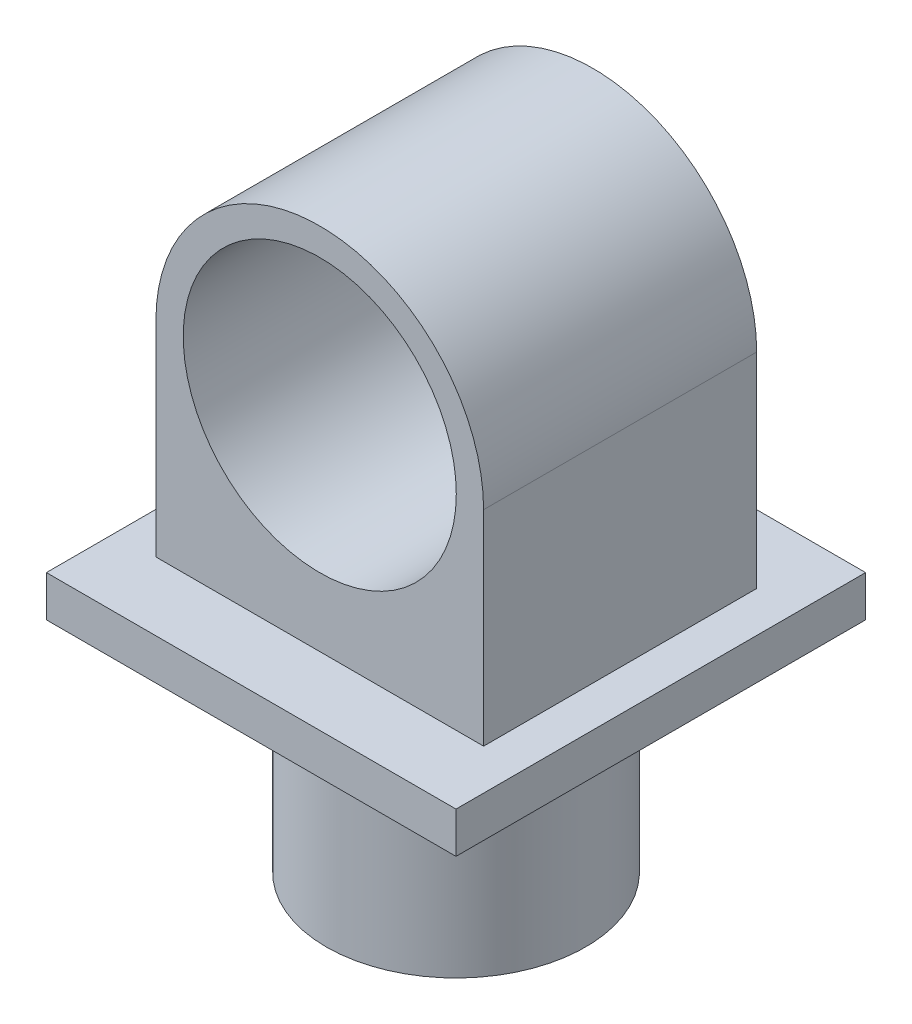
from build123d import *

# Parameters (mm, degrees)
SKETCH1_R           = 47.5
BOSS_EXTRUDE1_DEPTH = 80
SKETCH6_W           = 150
SKETCH6_H           = 150
BOSS_EXTRUDE3_DEPTH = 15
SKETCH7_R           = 50
BOSS_EXTRUDE4_DEPTH = 50


with BuildPart() as part:
    # Sketch1 → Boss-Extrude1 (new body)
    with BuildSketch(Plane(origin=(0, 0, 0), x_dir=(1, 0, 0), z_dir=(0, 1, 0))):
        Circle(SKETCH1_R)
    extrude(amount=BOSS_EXTRUDE1_DEPTH)

    # Sketch6 → Boss-Extrude3 (add)
    with BuildSketch(Plane(origin=(0, 80, 0), x_dir=(1, 0, 0), z_dir=(0, 1, 0))):
        Rectangle(SKETCH6_W, SKETCH6_H)
    extrude(amount=BOSS_EXTRUDE3_DEPTH)

    # Sketch7 → Boss-Extrude4 (add, symmetric)
    with BuildSketch(Plane.XY):
        with BuildLine():
            Line((-59.89087621, 95), (60.10912379, 95))
            Line((60.10912379, 95), (60.10912379, 170))
            ThreePointArc((60.10912379, 170), (0.10912379, 230), (-59.89087621, 170))
            Line((-59.89087621, 170), (-59.89087621, 95))
        make_face()
        with Locations((0.10912379, 170)):
            Circle(SKETCH7_R, mode=Mode.SUBTRACT)
    extrude(amount=BOSS_EXTRUDE4_DEPTH, both=True)


solid = part.part
